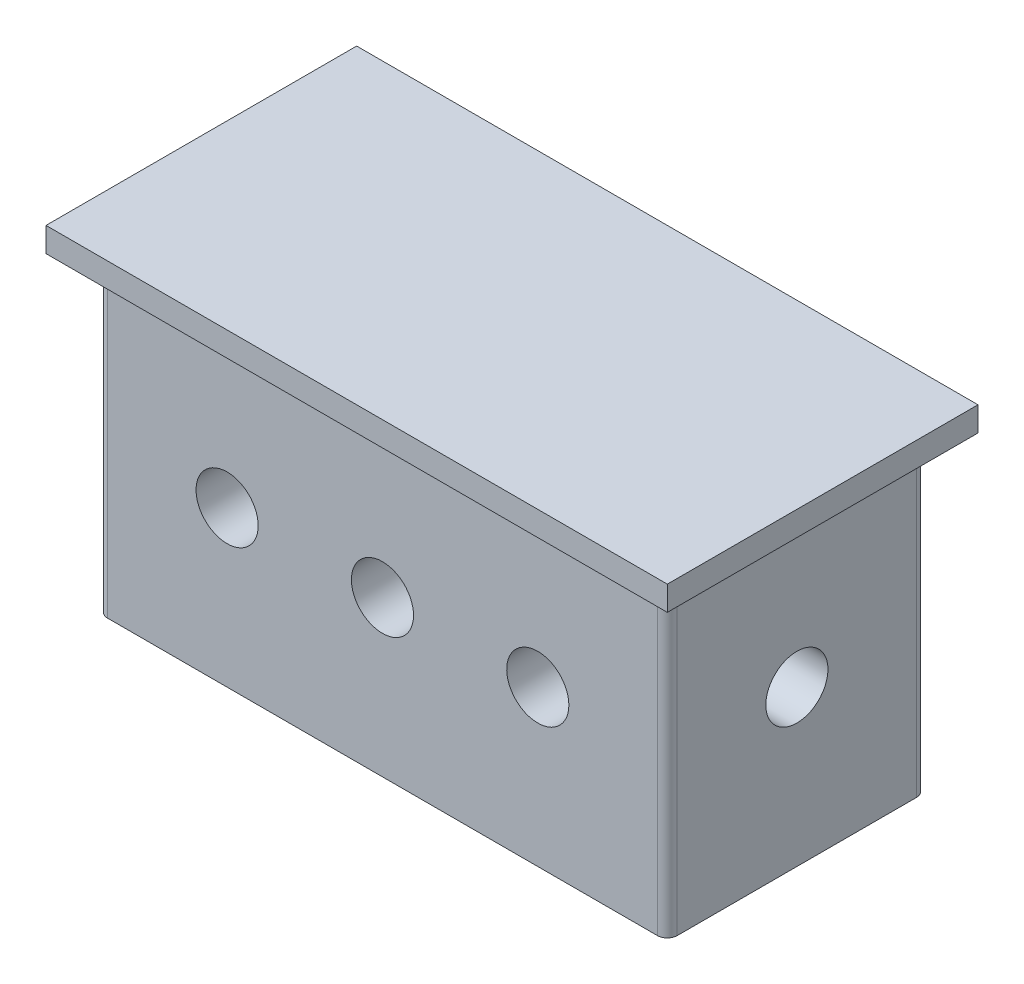
from build123d import *

# Parameters (mm, degrees)
SKETCH2_W           = 50.8
SKETCH2_H           = 25.4
BOSS_EXTRUDE2_DEPTH = 1.999996
SKETCH2_4_W         = 46.5836
SKETCH2_4_H         = 21.1836
BOSS_EXTRUDE3_DEPTH = 25.4
FILLET3_R           = 0.810638298
SKETCH3_R           = 2.54
CUT_EXTRUDE1_DEPTH  = 61.507944827
SKETCH4_R           = 2.54
CUT_EXTRUDE2_DEPTH  = 62.386545327


with BuildPart() as part:
    # Sketch2 → Boss-Extrude2 (new body)
    with BuildSketch(Plane(origin=(0, 0, 0), x_dir=(1, 0, 0), z_dir=(0, 1, 0))):
        with Locations((25.4, 12.7)):
            Rectangle(SKETCH2_W, SKETCH2_H)
    extrude(amount=BOSS_EXTRUDE2_DEPTH)

    # Sketch2_4 → Boss-Extrude3 (add)
    with BuildSketch(Plane(origin=(0, 0, 0), x_dir=(1, 0, 0), z_dir=(0, 1, 0))):
        with Locations((25.4, 12.7)):
            Rectangle(SKETCH2_4_W, SKETCH2_4_H)
    extrude(amount=-BOSS_EXTRUDE3_DEPTH)

    # Fillet3
    fillet3_edges = [part.edges().sort_by_distance(p)[0] for p in [
        (2.1082, -12.7, -23.2918),
        (48.6918, -12.7, -2.1082),
        (2.1082, -12.7, -2.1082),
        (48.6918, -12.7, -23.2918),
    ]]
    fillet(fillet3_edges, radius=FILLET3_R)

    # Sketch3 → Cut-Extrude1 (cut, through all)
    with BuildSketch(Plane(origin=(48.6918, 0, 0), x_dir=(0, 0, -1), z_dir=(1, 0, 0))):
        with Locations((12.7, -12.7)):
            Circle(SKETCH3_R)
    extrude(amount=-CUT_EXTRUDE1_DEPTH, mode=Mode.SUBTRACT)

    # Sketch4 → Cut-Extrude2 (cut, through all)
    with BuildSketch(Plane(origin=(0, 0, -23.2918), x_dir=(-1, 0, 0), z_dir=(0, 0, -1))):
        with Locations((-25.4, -12.7)):
            Circle(SKETCH4_R)
        with Locations((-38.1, -12.7)):
            Circle(SKETCH4_R)
        with Locations((-12.7, -12.7)):
            Circle(SKETCH4_R)
    extrude(amount=-CUT_EXTRUDE2_DEPTH, mode=Mode.SUBTRACT)


solid = part.part
